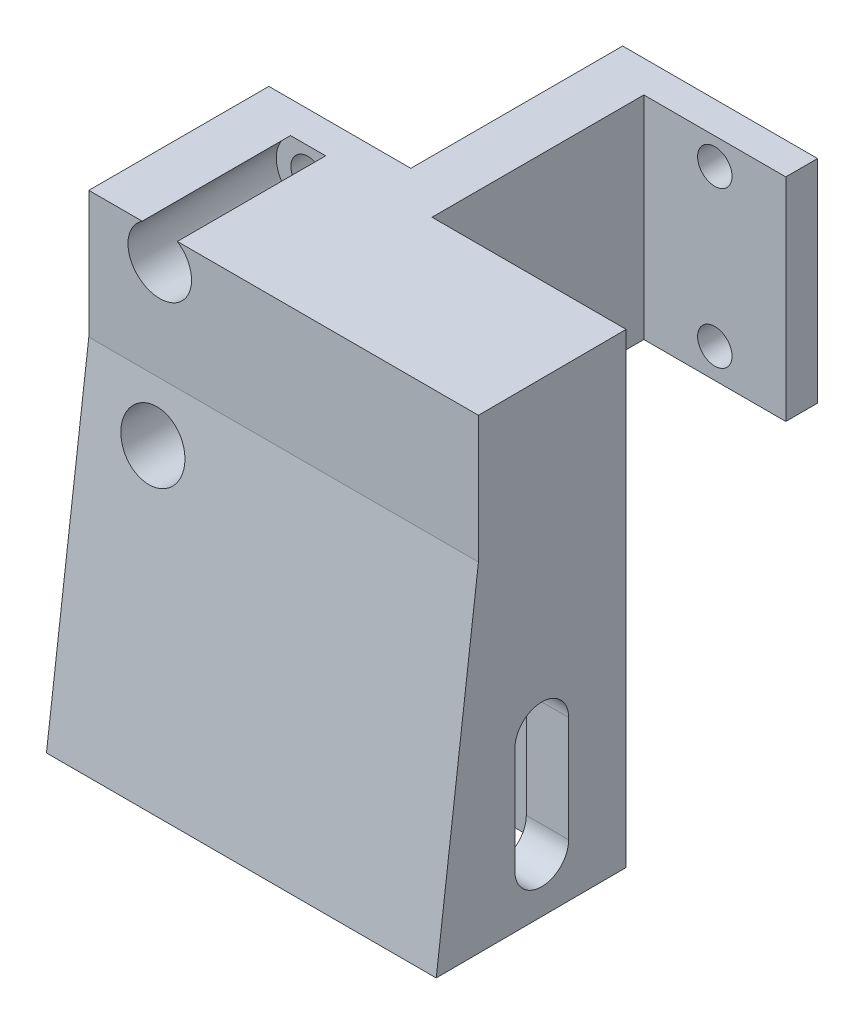
from build123d import *

# Parameters (mm, degrees)
BOSS_EXTRUDE1_DEPTH              = 20
CUT_EXTRUDE1_START               = -4
SKETCH2_R                        = 1.625
CUT_EXTRUDE1_DEPTH               = 25
BOSS_EXTRUDE2_DEPTH              = 36.8
SKETCH8_R                        = 3
CUT_EXTRUDE5_DEPTH               = 19
CUT_EXTRUDE6_DEPTH               = 45
CUT_EXTRUDE7_REACH               = 42.8
CUT_EXTRUDE7_OFFSET_FROM_SURFACE = 4


with BuildPart() as part:
    # Sketch1 → Boss-Extrude1 (new body)
    with BuildSketch(Plane(origin=(0, 0, 0), x_dir=(1, 0, 0), z_dir=(0, 1, 0))):
        Polygon((0, 0), (18.4, 0), (18.4, 20), (31.8, 20), (31.8, 23), (13.4, 23), (13.4, 3), (0, 3), align=None)
    extrude(amount=BOSS_EXTRUDE1_DEPTH)

    # Sketch2 → Cut-Extrude1 (cut)
    with BuildSketch(Plane.XY.offset(-20).offset(CUT_EXTRUDE1_START)):
        with Locations((25.1, 17.5)):
            Circle(SKETCH2_R)
        with Locations((25.1, 2.8)):
            Circle(SKETCH2_R)
    cut_extrude1 = extrude(amount=CUT_EXTRUDE1_DEPTH, mode=Mode.SUBTRACT)

    # Mirror1: Cut-Extrude1 across plane
    add(cut_extrude1.mirror(Plane.ZY.offset(-15.9)), mode=Mode.SUBTRACT)

    # Sketch5 → Boss-Extrude2 (add)
    with BuildSketch(Plane.ZY):
        Polygon((0, 20), (0, -24), (18, -24), (14, 8), (14, 20), align=None)
        with BuildLine():
            Line((10.55, -9), (10.55, -19))
            ThreePointArc((10.55, -19), (8, -21.55), (5.45, -19))
            Line((5.45, -19), (5.45, -9))
            ThreePointArc((5.45, -9), (8, -6.45), (10.55, -9))
        make_face(mode=Mode.SUBTRACT)
    extrude(amount=-BOSS_EXTRUDE2_DEPTH)

    # Sketch8 → Cut-Extrude5 (cut, through all)
    with BuildSketch(Plane(origin=(0, 0, 0), x_dir=(-1, 0, 0), z_dir=(0, 0, -1))):
        with Locations((-6.7, 2.8)):
            Circle(SKETCH8_R)
        with Locations((-6.7, 17.5)):
            Circle(SKETCH8_R)
    extrude(amount=-CUT_EXTRUDE5_DEPTH, mode=Mode.SUBTRACT)

    # Sketch6 → Cut-Extrude6 (cut, through all)
    with BuildSketch(Plane.XZ.offset(24)):
        Polygon((36.8, 18), (36.8, 0), (36.730884622, 0), align=None)
    extrude(amount=-CUT_EXTRUDE6_DEPTH, mode=Mode.SUBTRACT)

    # Cut-Extrude7: up to this face of the body (flat: up to its plane, moved by the offset)
    cut_extrude7_end = Plane(part.part.faces().sort_by_distance((36.760677184, -1.783418912, 7.75899858))[0]).offset(-CUT_EXTRUDE7_OFFSET_FROM_SURFACE)
    # Sketch7 → Cut-Extrude7 (cut, up to the picked face)
    with BuildSketch(Plane.ZY, mode=Mode.PRIVATE) as cut_extrude7_sk1:
        with BuildLine():
            Line((14, -24), (14, -9))
            ThreePointArc((14, -9), (8, -3), (2, -9))
            Line((2, -9), (2, -24))
            Line((2, -24), (14, -24))
        make_face()
    cut_extrude7_tool1 = split(extrude(cut_extrude7_sk1.sketch, amount=-CUT_EXTRUDE7_REACH, mode=Mode.PRIVATE), bisect_by=cut_extrude7_end, keep=Keep.BOTH, mode=Mode.PRIVATE)
    add(cut_extrude7_tool1.solids().sort_by_distance((0, -14.098317, 8))[0], mode=Mode.SUBTRACT)


solid = part.part
